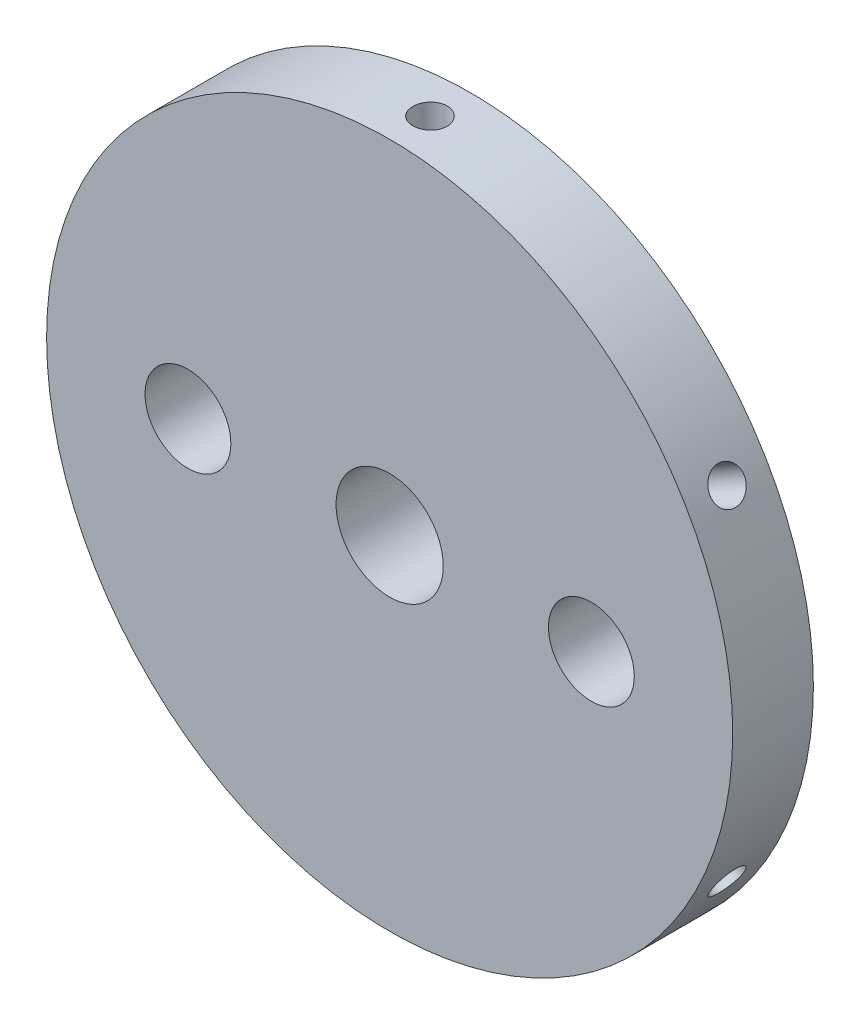
from build123d import *

# Parameters (mm, degrees)
SKETCH2_R                = 27
BOSS_EXTRUDE1_DEPTH      = 3.175
F_5_16_CLEARANCE_HOLE1_D = 8.4328
F_1_4_CLEARANCE_HOLE1_D  = 6.7564
CIRPATTERN1_COUNT        = 6


with BuildPart() as part:
    # Sketch2 → Boss-Extrude1 (new body, symmetric)
    with BuildSketch(Plane.XY):
        Circle(SKETCH2_R)
    extrude(amount=BOSS_EXTRUDE1_DEPTH, both=True)

    # 5/16 Clearance Hole1 (through all)
    with Locations(Plane.XY.offset(3.175)):
        with Locations((0, 0)):
            Hole(F_5_16_CLEARANCE_HOLE1_D / 2)

    # 1/4 Clearance Hole1 (through all)
    with Locations(Plane.XY.offset(3.175)):
        with Locations((-15.875, 0), (15.875, 0)):
            Hole(F_1_4_CLEARANCE_HOLE1_D / 2)

    # Sketch9 → Tap Drill for #6-32 Tap1 (revolve, cut)
    with BuildSketch(Plane(origin=(0, 27, 0), x_dir=(0, 0, 1), z_dir=(1, 0, 0))):
        Polygon((0, 0), (0, 7.16269403), (1.35255, 6.35), (1.35255, 0), align=None)
    tap_drill_for_6_32_tap1 = revolve(axis=Axis((0, 33.35, 0), (0, -1, 0)), mode=Mode.SUBTRACT)

    # CirPattern1: Tap Drill for #6-32 Tap1 ×6 about axis
    cirpattern1_axis = Axis((0, 0, 3.175), (0, 0, 1))
    for i in range(1, CIRPATTERN1_COUNT):
        add(tap_drill_for_6_32_tap1.rotate(cirpattern1_axis, i * 360 / CIRPATTERN1_COUNT), mode=Mode.SUBTRACT)


solid = part.part
